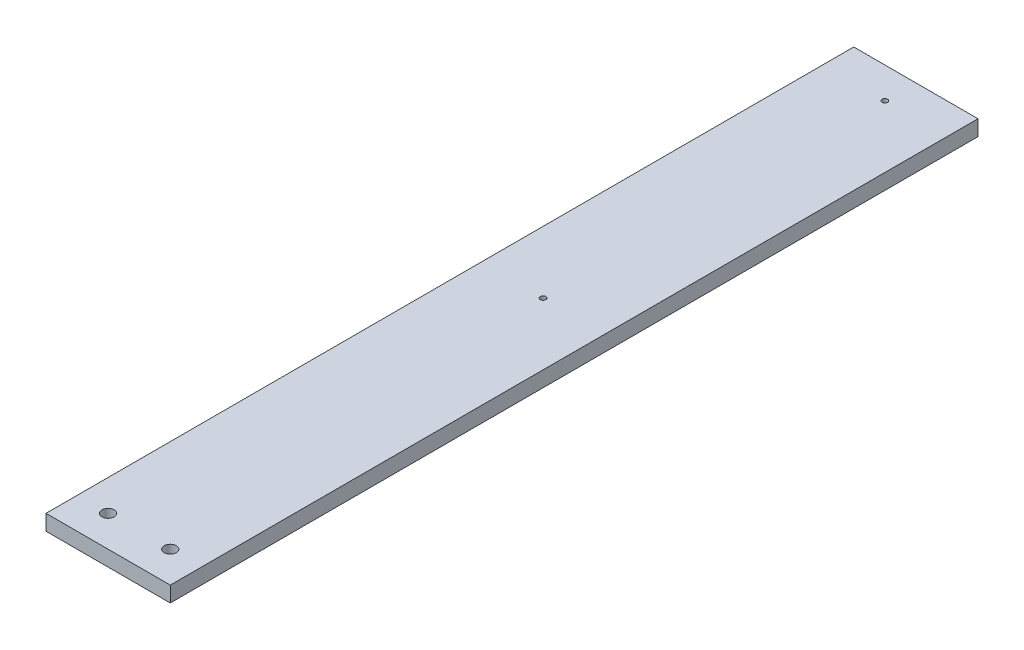
from build123d import *

# Parameters (mm, degrees)
SKETCH1_W                 = 50.8
SKETCH1_H                 = 6.35
EXTRUDE_THIN1_DEPTH       = 330.2
SKETCH3_R                 = 2.4892
CUT_EXTRUDE1_DEPTH        = 7.35
F_4_40_TAPPED_HOLE1_D     = 2.2606
F_4_40_TAPPED_HOLE1_DEPTH = 7.62
F_4_40_TAPPED_HOLE1_TIP   = 0.679152758


with BuildPart() as part:
    # Sketch1 → Extrude-Thin1 (new body)
    with BuildSketch(Plane.XY):
        with Locations((25.4, -3.175)):
            Rectangle(SKETCH1_W, SKETCH1_H)
    extrude(amount=EXTRUDE_THIN1_DEPTH)

    # Sketch3 → Cut-Extrude1 (cut, through all)
    with BuildSketch(Plane(origin=(0, 0, 0), x_dir=(1, 0, 0), z_dir=(0, 1, 0))):
        with Locations((12.7, -317.5)):
            Circle(SKETCH3_R)
        with Locations((38.1, -317.5)):
            Circle(SKETCH3_R)
    extrude(amount=-CUT_EXTRUDE1_DEPTH, mode=Mode.SUBTRACT)

    # #4-40 Tapped Hole1
    with Locations(Plane(origin=(0, 0, 0), x_dir=(1, 0, 0), z_dir=(0, 1, 0))):
        with Locations((25.4, -152.4), (25.4, -12.7)):
            Hole(F_4_40_TAPPED_HOLE1_D / 2, depth=F_4_40_TAPPED_HOLE1_DEPTH)
            with Locations((0, 0, -(F_4_40_TAPPED_HOLE1_DEPTH + F_4_40_TAPPED_HOLE1_TIP / 2))):  # 118° drill point
                Cone(0, F_4_40_TAPPED_HOLE1_D / 2, F_4_40_TAPPED_HOLE1_TIP, mode=Mode.SUBTRACT)


solid = part.part
